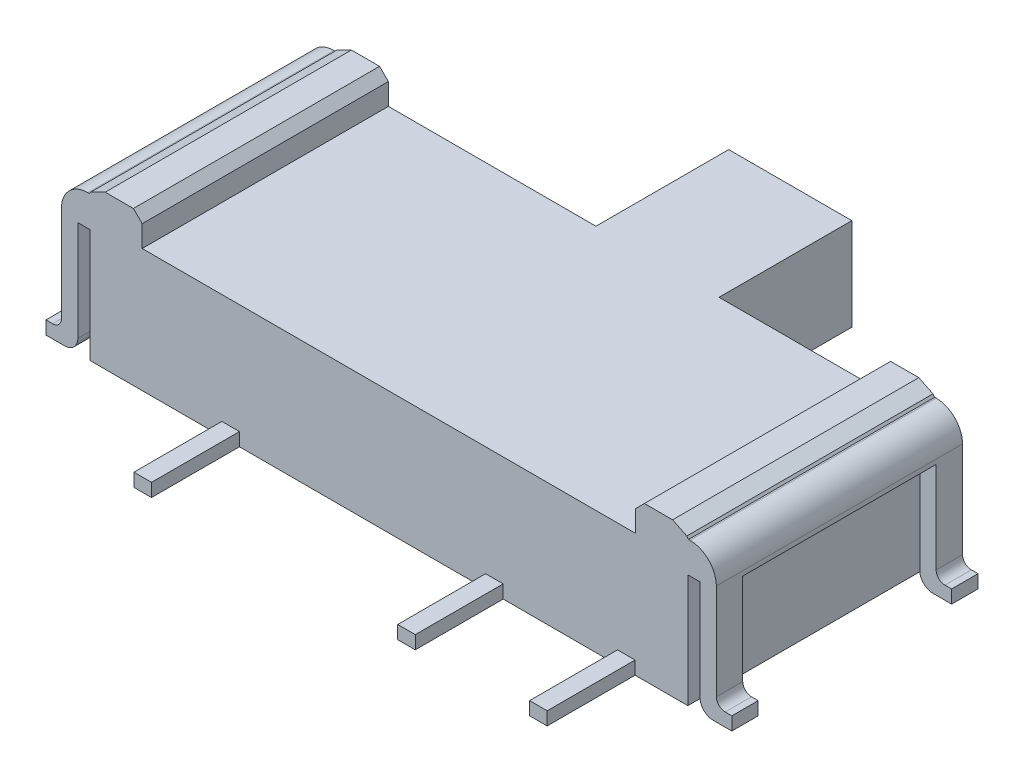
from build123d import *

# Parameters (mm, degrees)
SKETCH1_W             = 6.8
SKETCH1_H             = 2.8
BOSS_EXTRUDE1_DEPTH   = 1.4
BOSS_EXTRUDE2_DEPTH   = 2.8
BOSS_EXTRUDE2_2_DEPTH = 2.8
BOSS_EXTRUDE3_DEPTH   = 2.8
CUT_EXTRUDE1_DEPTH    = 1.1
SKETCH8_W             = 0.2
SKETCH8_H             = 1
BOSS_EXTRUDE4_DEPTH   = 0.15
SKETCH9_W             = 1.4
SKETCH9_H             = 1.05
BOSS_EXTRUDE5_DEPTH   = 1.51


with BuildPart() as part:
    # Sketch1 → Boss-Extrude1 (new body)
    with BuildSketch(Plane(origin=(0, 0, 0), x_dir=(1, 0, 0), z_dir=(0, 1, 0))):
        Rectangle(SKETCH1_W, SKETCH1_H)
    extrude(amount=BOSS_EXTRUDE1_DEPTH)



with BuildPart() as body_2:
    # Sketch3 → Boss-Extrude2 (new body)
    with BuildSketch(Plane.XY.offset(1.4)):
        with BuildLine():
            Line((-3.9, 0), (-3.687815007, 0))
            ThreePointArc((-3.687815007, 0), (-3.58174899, 0.043933983), (-3.537815007, 0.15))
            Line((-3.537815007, 0.15), (-3.537815007, 1.44554352))
            Line((-3.537815007, 1.44554352), (-2.932940076, 1.44554352))
            Line((-2.932940076, 1.44554352), (-2.932940076, 1.641087041))
            Line((-2.932940076, 1.641087041), (-3.424164264, 1.641087041))
            ThreePointArc((-3.424164264, 1.641087041), (-3.636296298, 1.553219075), (-3.724164264, 1.341087041))
            Line((-3.724164264, 1.341087041), (-3.724164264, 0.25))
            ThreePointArc((-3.724164264, 0.25), (-3.753453586, 0.179289322), (-3.824164264, 0.15))
            Line((-3.824164264, 0.15), (-3.9, 0.15))
            Line((-3.9, 0.15), (-3.9, 0))
        make_face()
    extrude(amount=-BOSS_EXTRUDE2_DEPTH)


with BuildPart() as body_3:
    # Sketch3 → Boss-Extrude2 2 (new body)
    with BuildSketch(Plane.XY.offset(1.4)):
        with BuildLine():
            Line((3.824164264, 0.15), (3.9, 0.15))
            Line((3.9, 0.15), (3.9, 0))
            Line((3.9, 0), (3.687815007, 0))
            ThreePointArc((3.687815007, 0), (3.58174899, 0.043933983), (3.537815007, 0.15))
            Line((3.537815007, 0.15), (3.537815007, 1.44554352))
            Line((3.537815007, 1.44554352), (2.932940076, 1.44554352))
            Line((2.932940076, 1.44554352), (2.932940076, 1.641087041))
            Line((2.932940076, 1.641087041), (3.424164264, 1.641087041))
            ThreePointArc((3.424164264, 1.641087041), (3.636296298, 1.553219075), (3.724164264, 1.341087041))
            Line((3.724164264, 1.341087041), (3.724164264, 0.25))
            ThreePointArc((3.724164264, 0.25), (3.753453586, 0.179289322), (3.824164264, 0.15))
        make_face()
    extrude(amount=-BOSS_EXTRUDE2_2_DEPTH)


with BuildPart() as part_1:
    add(part.part)

    add(body_2.part)  # Boss-Extrude3 merges body 2

    add(body_3.part)  # Boss-Extrude3 merges body 3
    # Sketch4 → Boss-Extrude3 (add)
    with BuildSketch(Plane.XY.offset(1.4)):
        Polygon((-2.805997344, 1.4), (-2.805997344, 1.644514916), (-2.905997344, 1.744514916), (-3.226717158, 1.744514916), (-3.38829441, 1.665722517), (-3.621220366, 1.367677477), (-3.582797618, 1.288885079), (-2.805997344, 1.288885079), align=None)
        Polygon((3.582797618, 1.288885079), (2.805997344, 1.288885079), (2.805997344, 1.4), (2.805997344, 1.644514916), (2.905997344, 1.744514916), (3.226717158, 1.744514916), (3.38829441, 1.665722517), (3.621220366, 1.367677477), align=None)
    extrude(amount=-BOSS_EXTRUDE3_DEPTH)

    # Sketch6 → Cut-Extrude1 (cut, symmetric)
    with BuildSketch(Plane.XY):
        with BuildLine():
            Line((-3.537815007, 1.288885079), (-3.724164264, 1.288885079))
            Line((-3.724164264, 1.288885079), (-3.724164264, 0.25))
            ThreePointArc((-3.724164264, 0.25), (-3.753453586, 0.179289322), (-3.824164264, 0.15))
            Line((-3.824164264, 0.15), (-3.9, 0.15))
            Line((-3.9, 0.15), (-3.9, 0))
            Line((-3.9, 0), (-3.687815007, 0))
            ThreePointArc((-3.687815007, 0), (-3.58174899, 0.043933983), (-3.537815007, 0.15))
            Line((-3.537815007, 0.15), (-3.537815007, 1.288885079))
        make_face()
        with BuildLine():
            Line((3.537815007, 1.288885079), (3.724164264, 1.288885079))
            Line((3.724164264, 1.288885079), (3.724164264, 0.25))
            ThreePointArc((3.724164264, 0.25), (3.753453586, 0.179289322), (3.824164264, 0.15))
            Line((3.824164264, 0.15), (3.9, 0.15))
            Line((3.9, 0.15), (3.9, 0))
            Line((3.9, 0), (3.687815007, 0))
            ThreePointArc((3.687815007, 0), (3.58174899, 0.043933983), (3.537815007, 0.15))
            Line((3.537815007, 0.15), (3.537815007, 1.288885079))
        make_face()
    extrude(amount=CUT_EXTRUDE1_DEPTH, both=True, mode=Mode.SUBTRACT)

    # Sketch8 → Boss-Extrude4 (add)
    with BuildSketch(Plane.XZ):
        with Locations((-1.8, 1.9)):
            Rectangle(SKETCH8_W, SKETCH8_H)
        with Locations((1.2, 1.9)):
            Rectangle(SKETCH8_W, SKETCH8_H)
        with Locations((2.7, 1.9)):
            Rectangle(SKETCH8_W, SKETCH8_H)
    extrude(amount=-BOSS_EXTRUDE4_DEPTH)

    # Sketch9 → Boss-Extrude5 (add)
    with BuildSketch(Plane(origin=(0, 0, -1.4), x_dir=(-1, 0, 0), z_dir=(0, 0, -1))):
        with Locations((-0.254692735, 0.875)):
            Rectangle(SKETCH9_W, SKETCH9_H)
    extrude(amount=BOSS_EXTRUDE5_DEPTH)


solid = part_1.part
